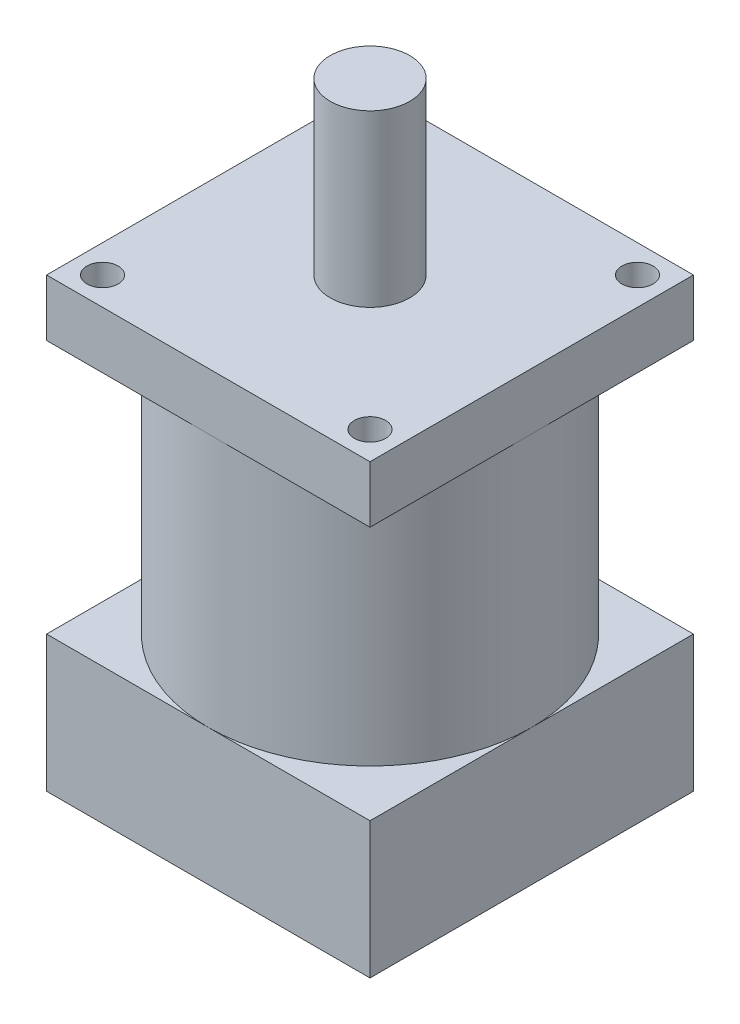
from build123d import *

# Parameters (mm, degrees)
SKETCH_1_W          = 57
SKETCH_1_H          = 57
EXTRUDE_3_DEPTH     = 24
SKETCH_3_R          = 28.5
EXTRUDE_4_DEPTH     = 44.8
SKETCH_4_W          = 57
SKETCH_4_H          = 57
EXTRUDE_5_DEPTH     = 10
SKETCH_6_R          = 7
EXTRUDE_6_DEPTH     = 30
SKETCH_7_R          = 2.75
CUT_EXTRUDE_1_DEPTH = 30
SKETCH_8_R          = 2
CUT_EXTRUDE_2_DEPTH = 5


with BuildPart() as part:
    # 草图1 → 凸台-拉伸3 (new body)
    with BuildSketch(Plane(origin=(0, 0, 0), x_dir=(1, 0, 0), z_dir=(0, 1, 0))):
        Rectangle(SKETCH_1_W, SKETCH_1_H)
    extrude(amount=EXTRUDE_3_DEPTH)

    # 草图3 → 凸台-拉伸4 (add)
    with BuildSketch(Plane(origin=(0, 24, 0), x_dir=(1, 0, 0), z_dir=(0, 1, 0))):
        Circle(SKETCH_3_R)
    extrude(amount=EXTRUDE_4_DEPTH)

    # 草图4 → 凸台-拉伸5 (add)
    with BuildSketch(Plane(origin=(0, 68.8, 0), x_dir=(1, 0, 0), z_dir=(0, 1, 0))):
        Rectangle(SKETCH_4_W, SKETCH_4_H)
    extrude(amount=EXTRUDE_5_DEPTH)

    # 草图6 → 凸台-拉伸6 (add)
    with BuildSketch(Plane(origin=(0, 78.8, 0), x_dir=(1, 0, 0), z_dir=(0, 1, 0))):
        Circle(SKETCH_6_R)
    extrude(amount=EXTRUDE_6_DEPTH)

    # 草图7 → 切除-拉伸1 (cut)
    with BuildSketch(Plane(origin=(0, 78.8, 0), x_dir=(1, 0, 0), z_dir=(0, 1, 0))):
        with Locations((23.57, -23.57)):
            Circle(SKETCH_7_R)
        with Locations((-23.57, -23.57)):
            Circle(SKETCH_7_R)
        with Locations((-23.57, 23.57)):
            Circle(SKETCH_7_R)
        with Locations((23.57, 23.57)):
            Circle(SKETCH_7_R)
    extrude(amount=-CUT_EXTRUDE_1_DEPTH, mode=Mode.SUBTRACT)

    # 草图8 → 切除-拉伸2 (cut)
    with BuildSketch(Plane(origin=(0, 0, 0), x_dir=(-1, 0, 0), z_dir=(0, -1, 0))):
        with Locations((23.57, 23.57)):
            Circle(SKETCH_8_R)
        with Locations((-23.57, 23.57)):
            Circle(SKETCH_8_R)
        with Locations((-23.57, -23.57)):
            Circle(SKETCH_8_R)
        with Locations((23.57, -23.57)):
            Circle(SKETCH_8_R)
    extrude(amount=-CUT_EXTRUDE_2_DEPTH, mode=Mode.SUBTRACT)


solid = part.part
